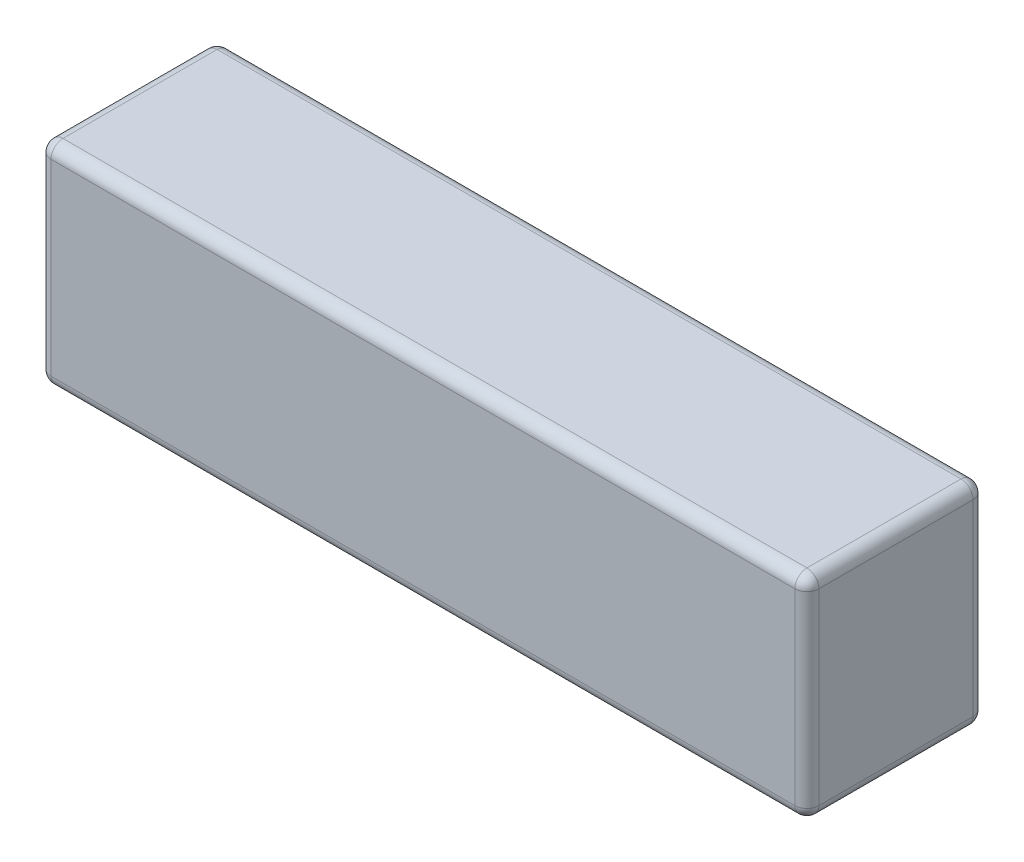
from build123d import *

# Parameters (mm, degrees)
SKETCH1_W           = 319
SKETCH1_H           = 88
BOSS_EXTRUDE1_DEPTH = 74
FILLET1_R           = 5


with BuildPart() as part:
    # Sketch1 → Boss-Extrude1 (new body)
    with BuildSketch(Plane.XY):
        Rectangle(SKETCH1_W, SKETCH1_H)
    extrude(amount=BOSS_EXTRUDE1_DEPTH)

    # Fillet1
    fillet1_edges = [part.edges().sort_by_distance(p)[0] for p in [
        (159.5, 0, 74),
        (0, -44, 74),
        (-159.5, 0, 74),
        (0, -44, 0),
        (159.5, 0, 0),
        (0, 44, 0),
        (-159.5, 0, 0),
        (-159.5, -44, 37),
        (159.5, -44, 37),
        (159.5, 44, 37),
        (-159.5, 44, 37),
        (0, 44, 74),
    ]]
    fillet(fillet1_edges, radius=FILLET1_R)


solid = part.part
